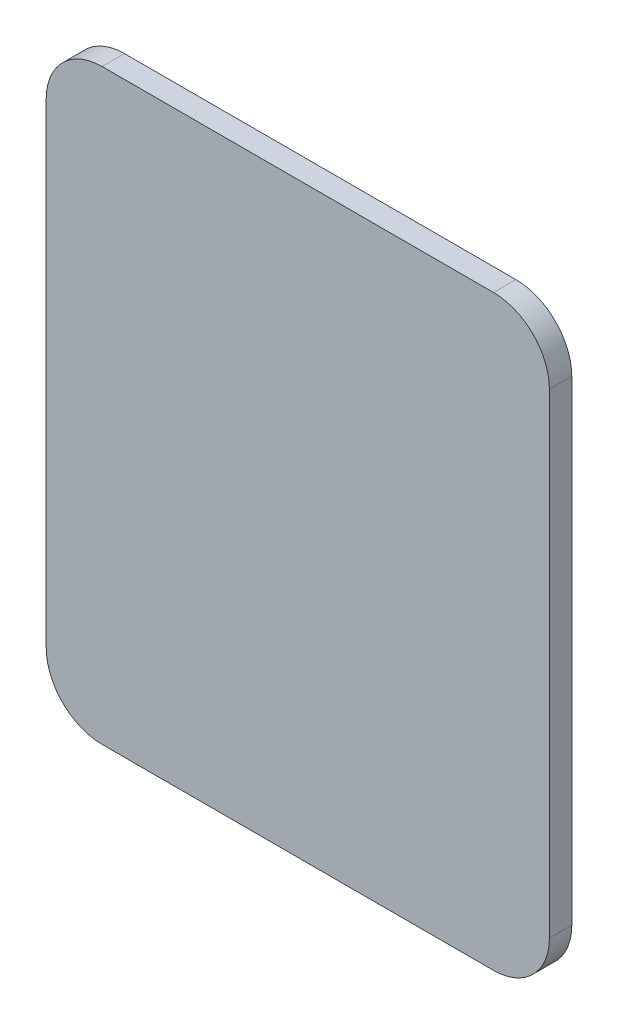
from build123d import *

# Parameters (mm, degrees)
SKETCH_1_W      = 18
SKETCH_1_H      = 21
EXTRUDE_1_DEPTH = 0.4
FILLET_1_R      = 2


with BuildPart() as part:
    # Эскиз1 → Бобышка-Вытянуть1 (new body, symmetric)
    with BuildSketch(Plane.XY):
        Rectangle(SKETCH_1_W, SKETCH_1_H)
    extrude(amount=EXTRUDE_1_DEPTH, both=True)

    # Скругление1
    fillet_1_edges = [part.edges().sort_by_distance(p)[0] for p in [
        (9, -10.5, 0),
        (-9, -10.5, 0),
        (-9, 10.5, 0),
        (9, 10.5, 0),
    ]]
    fillet(fillet_1_edges, radius=FILLET_1_R)


solid = part.part
